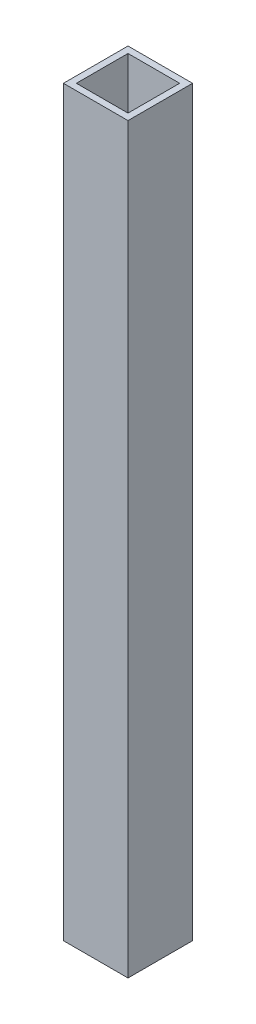
from build123d import *

# Parameters (mm, degrees)
SKETCH1_W           = 20
SKETCH1_H           = 230
BOSS_EXTRUDE1_DEPTH = 20
SKETCH2_W           = 16
SKETCH2_H           = 16
CUT_EXTRUDE1_DEPTH  = 200


with BuildPart() as part:
    # Sketch1 → Boss-Extrude1 (new body)
    with BuildSketch(Plane.XY):
        with Locations((-21.739130435, -65.217391304)):
            Rectangle(SKETCH1_W, SKETCH1_H)
    extrude(amount=-BOSS_EXTRUDE1_DEPTH)

    # Sketch2 → Cut-Extrude1 (cut)
    with BuildSketch(Plane(origin=(0, 49.782608696, 0), x_dir=(1, 0, 0), z_dir=(0, 1, 0))):
        with Locations((-21.739130435, 10)):
            Rectangle(SKETCH2_W, SKETCH2_H)
    extrude(amount=-CUT_EXTRUDE1_DEPTH, mode=Mode.SUBTRACT)


solid = part.part
